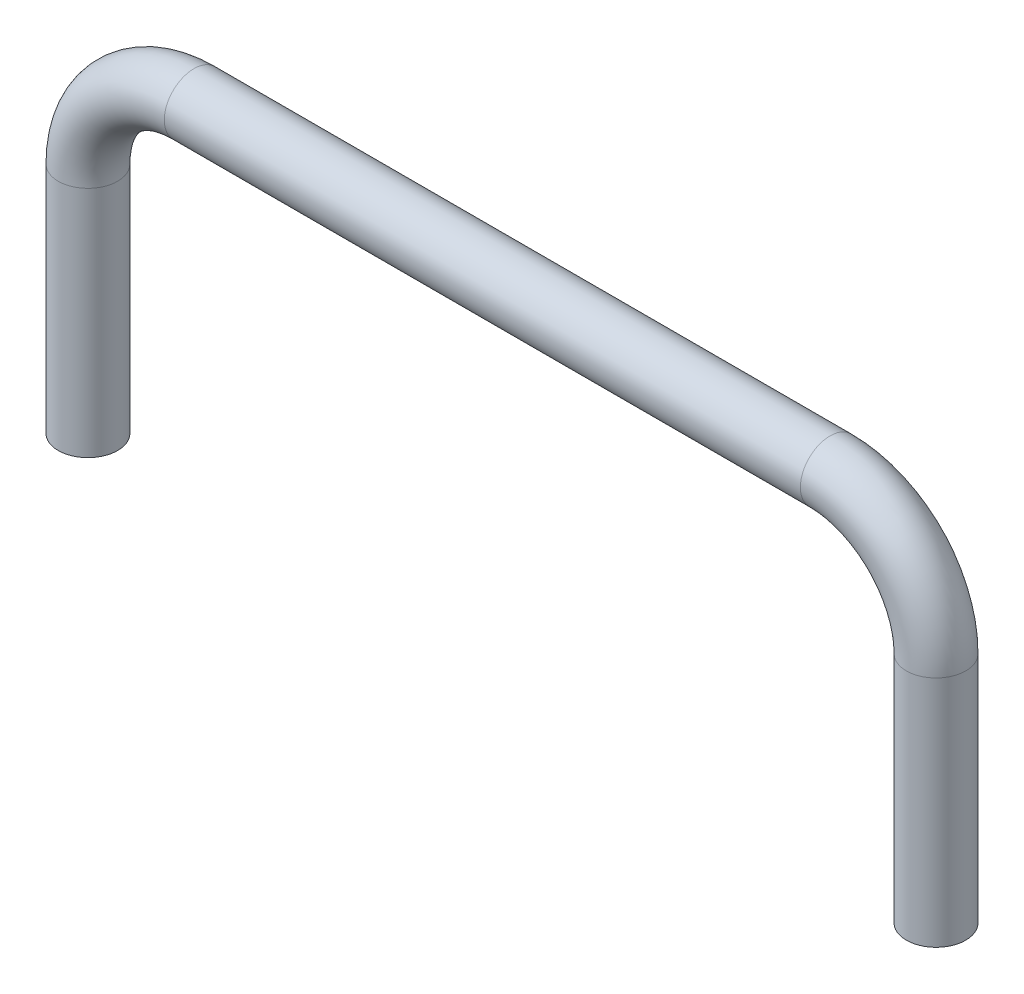
from build123d import *

# Parameters (mm, degrees)
SKETCH2_R = 0.7


with BuildPart() as part:
    # Sweep1: sweep along a path in Sketch1
    with BuildLine(Plane.XY) as sweep1_path:
        Line((0, 0), (0, 5.5))
        ThreePointArc((0, 5.5), (0.732233047, 7.267766953), (2.5, 8))
        Line((2.5, 8), (17.5, 8))
        ThreePointArc((17.5, 8), (19.267766953, 7.267766953), (20, 5.5))
        Line((20, 5.5), (20, 0))
    # Sketch2 → Sweep1 (sweep)
    with BuildSketch(Plane(origin=(0, 0, 0), x_dir=(1, 0, 0), z_dir=(0, 1, 0))):
        Circle(SKETCH2_R)
    sweep(path=sweep1_path.line)


solid = part.part
